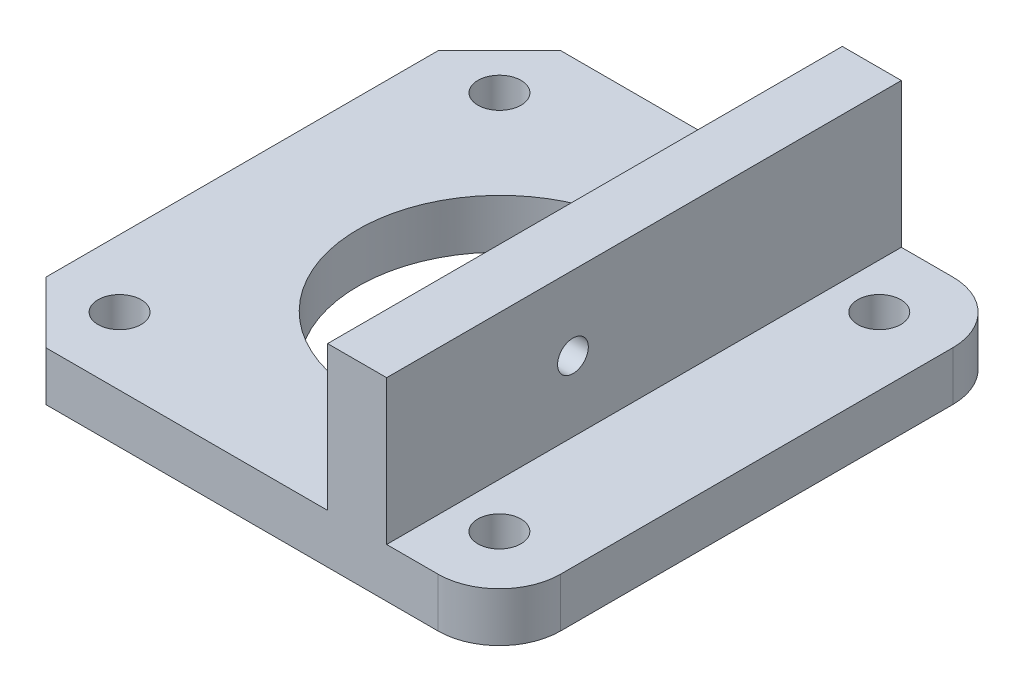
from build123d import *

# Parameters (mm, degrees)
SKETCH2_W           = 42
SKETCH2_H           = 42.01
BOSS_EXTRUDE2_DEPTH = 4.02
SKETCH3_W           = 4.82
SKETCH3_H           = 15.81
BOSS_EXTRUDE3_DEPTH = 42.01
SKETCH4_R           = 11.6
CUT_EXTRUDE1_DEPTH  = 4.02
SKETCH5_R           = 1.255
CUT_EXTRUDE2_DEPTH  = 33.803184685
CHAMFER1_SIZE       = 5
SKETCH6_R           = 1.76
CUT_EXTRUDE3_DEPTH  = 4.02
FILLET1_R           = 5
SKETCH7_R           = 2.515
BOSS_EXTRUDE4_DEPTH = 3.92
FILLET3_R           = 0.5


with BuildPart() as part:
    # Sketch2 → Boss-Extrude2 (new body)
    with BuildSketch(Plane(origin=(0, 0, 0), x_dir=(1, 0, 0), z_dir=(0, 1, 0))):
        with Locations((0.04, -0.105)):
            Rectangle(SKETCH2_W, SKETCH2_H)
        with BuildLine():
            Line((2.023352998, 16.161086645), (2.023352998, 11.422173289))
            ThreePointArc((2.023352998, 11.422173289), (-7.967970915, -8.430387861), (11.29, 2.663813057))
            Line((11.29, 2.663813057), (11.29, 16.161086645))
            Line((11.29, 16.161086645), (4.04, 16.161086645))
            Line((4.04, 16.161086645), (2.023352998, 16.161086645))
        make_face(mode=Mode.SUBTRACT)
    extrude(amount=BOSS_EXTRUDE2_DEPTH)

    # Sketch3 → Boss-Extrude3 (add)
    with BuildSketch(Plane.XY.offset(21.11)):
        with Locations((9.433184685, 7.905)):
            Rectangle(SKETCH3_W, SKETCH3_H)
    extrude(amount=-BOSS_EXTRUDE3_DEPTH)

    # Sketch4 → Cut-Extrude1 (cut)
    with BuildSketch(Plane.XZ):
        Circle(SKETCH4_R)
    extrude(amount=-CUT_EXTRUDE1_DEPTH, mode=Mode.SUBTRACT)

    # Sketch5 → Cut-Extrude2 (cut, through all)
    with BuildSketch(Plane(origin=(11.843184685, 0, 0), x_dir=(0, 0, -1), z_dir=(1, 0, 0))):
        with Locations((-5.905, 9.751921695)):
            Circle(SKETCH5_R)
    extrude(amount=-CUT_EXTRUDE2_DEPTH, mode=Mode.SUBTRACT)

    # Chamfer1
    chamfer1_edges = [part.edges().sort_by_distance(p)[0] for p in [
        (-20.96, 2.01, -20.9),
        (-20.96, 2.01, 21.11),
    ]]
    chamfer(chamfer1_edges, length=CHAMFER1_SIZE)

    # Sketch6 → Cut-Extrude3 (cut)
    with BuildSketch(Plane(origin=(0, 4.02, 0), x_dir=(1, 0, 0), z_dir=(0, 1, 0))):
        with Locations((-15.48, 15.42)):
            Circle(SKETCH6_R)
        with Locations((15.52, 15.42)):
            Circle(SKETCH6_R)
        with Locations((-15.48, -15.585900263)):
            Circle(SKETCH6_R)
        with Locations((15.52, -15.585900263)):
            Circle(SKETCH6_R)
    extrude(amount=-CUT_EXTRUDE3_DEPTH, mode=Mode.SUBTRACT)

    # Fillet1
    fillet1_edges = [part.edges().sort_by_distance(p)[0] for p in [
        (21.04, 2.01, -20.9),
        (21.04, 2.01, 21.11),
    ]]
    fillet(fillet1_edges, radius=FILLET1_R)

    # Sketch7 → Boss-Extrude4 (add)
    with BuildSketch(Plane.ZY.offset(-7.023184685)):
        with Locations((-13.936978862, 9.480319198)):
            Circle(SKETCH7_R)
    extrude(amount=BOSS_EXTRUDE4_DEPTH)

    # Fillet3
    fillet3_edges = [part.edges().sort_by_distance(p)[0] for p in [
        (3.103184685, 9.480319198, -16.451978862),
    ]]
    fillet(fillet3_edges, radius=FILLET3_R)


solid = part.part
